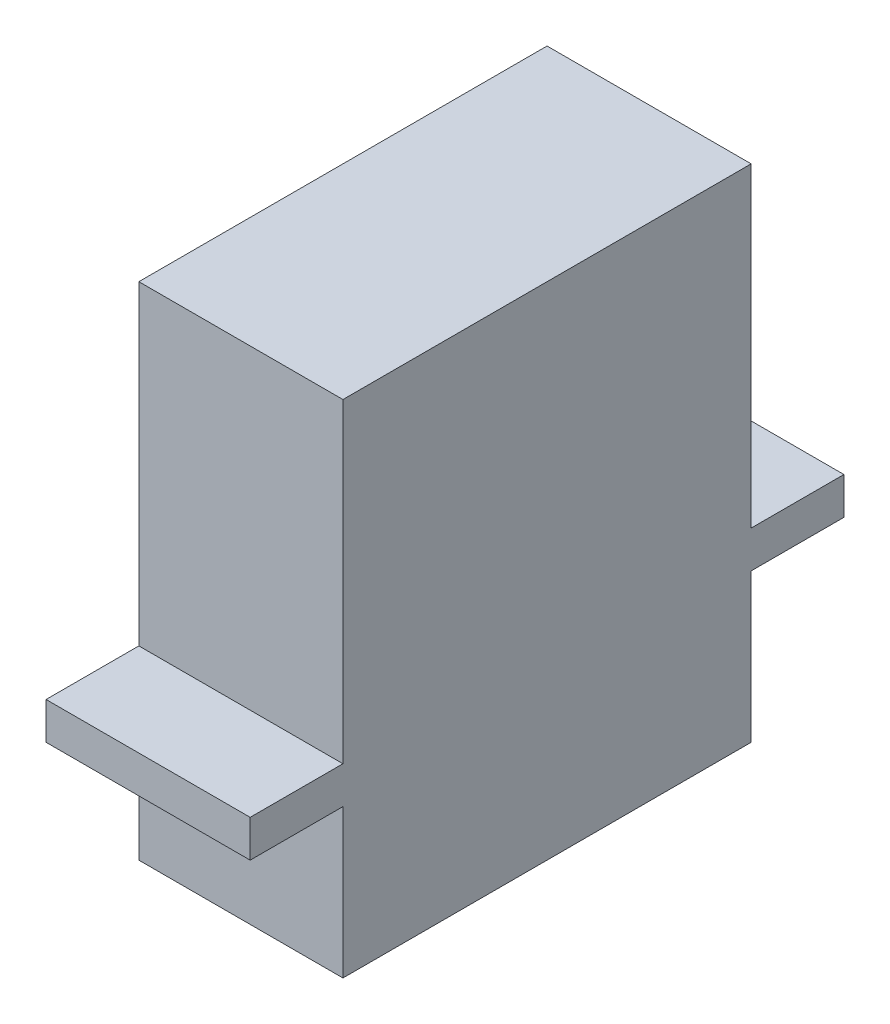
from build123d import *

# Parameters (mm, degrees)
SKETCH1_W           = 11
SKETCH1_H           = 22
BOSS_EXTRUDE1_DEPTH = 27
BOSS_EXTRUDE2_START = -8
SKETCH2_W           = 11
SKETCH2_H           = 5
BOSS_EXTRUDE2_DEPTH = 2


with BuildPart() as part:
    # Sketch1 → Boss-Extrude1 (new body)
    with BuildSketch(Plane(origin=(0, 0, 0), x_dir=(1, 0, 0), z_dir=(0, 1, 0))):
        with Locations((5.5, 11)):
            Rectangle(SKETCH1_W, SKETCH1_H)
    extrude(amount=BOSS_EXTRUDE1_DEPTH)

    # Sketch2 → Boss-Extrude2 (add)
    with BuildSketch(Plane.XZ.offset(BOSS_EXTRUDE2_START)):
        with Locations((5.5, 2.5)):
            Rectangle(SKETCH2_W, SKETCH2_H)
        with Locations((5.5, -24.5)):
            Rectangle(SKETCH2_W, SKETCH2_H)
    extrude(amount=-BOSS_EXTRUDE2_DEPTH)


solid = part.part
